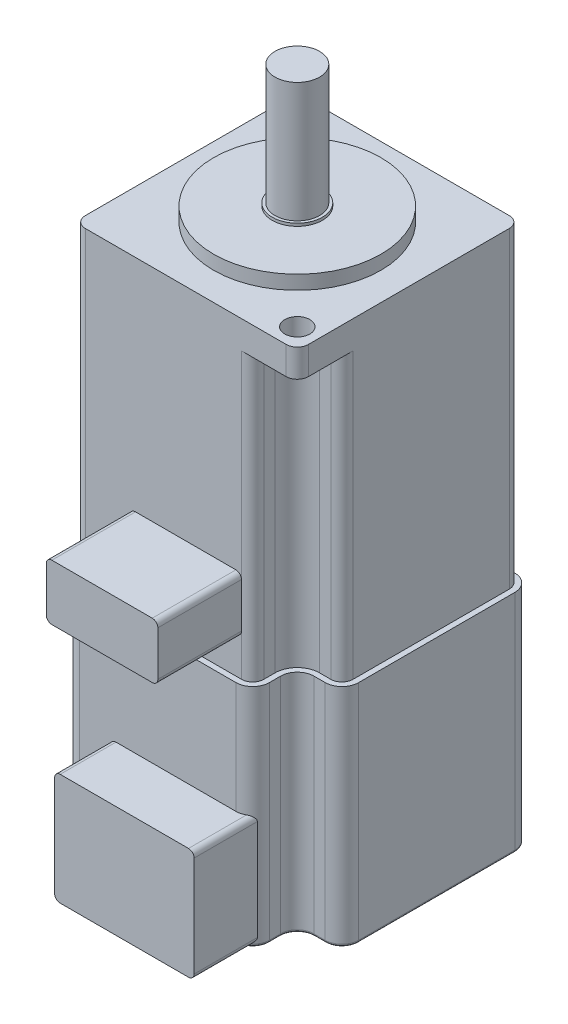
from build123d import *

# Parameters (mm, degrees)
BOSS_EXTRUDE1_DEPTH             = 5
SKETCH2_R                       = 15
BOSS_EXTRUDE2_DEPTH             = 2.5
SKETCH3_R                       = 2.25
CUT_EXTRUDE1_DEPTH              = 5
BOSS_EXTRUDE3_DEPTH             = 51
BOSS_EXTRUDE4_DEPTH             = 40.5
SKETCH6_R                       = 4.5
BOSS_EXTRUDE5_DEPTH             = 0.5
SKETCH7_R                       = 4
BOSS_EXTRUDE6_DEPTH             = 21.5
FILLET1_R                       = 0.5
BOSS_EXTRUDE7_DEPTH             = 15
BOSS_EXTRUDE8_DEPTH             = 10
BOSS_EXTRUDE8_DIRECTION_2_REACH = 44


with BuildPart() as part:
    # Sketch1 → Boss-Extrude1 (new body)
    with BuildSketch(Plane(origin=(0, 0, 0), x_dir=(1, 0, 0), z_dir=(0, 1, 0))):
        with BuildLine():
            Line((2, 0), (38, 0))
            ThreePointArc((38, 0), (39.414213562, 0.585786438), (40, 2))
            Line((40, 2), (40, 38))
            ThreePointArc((40, 38), (39.414213562, 39.414213562), (38, 40))
            Line((38, 40), (2, 40))
            ThreePointArc((2, 40), (0.585786438, 39.414213562), (0, 38))
            Line((0, 38), (0, 2))
            ThreePointArc((0, 2), (0.585786438, 0.585786438), (2, 0))
        make_face()
    extrude(amount=BOSS_EXTRUDE1_DEPTH)

    # Sketch2 → Boss-Extrude2 (add)
    with BuildSketch(Plane(origin=(0, 5, 0), x_dir=(1, 0, 0), z_dir=(0, 1, 0))):
        with Locations((20, 20)):
            Circle(SKETCH2_R)
    extrude(amount=BOSS_EXTRUDE2_DEPTH)

    # Sketch3 → Cut-Extrude1 (cut)
    with BuildSketch(Plane(origin=(0, 5, 0), x_dir=(1, 0, 0), z_dir=(0, 1, 0))):
        with Locations((3.736544033, 36.263455967)):
            Circle(SKETCH3_R)
        with Locations((36.263455967, 3.736544033)):
            Circle(SKETCH3_R)
    extrude(amount=-CUT_EXTRUDE1_DEPTH, mode=Mode.SUBTRACT)

    # Sketch4 → Boss-Extrude3 (add)
    with BuildSketch(Plane.XZ):
        with BuildLine():
            Line((32, -2), (32, -4))
            ThreePointArc((32, -4), (33.171572875, -6.828427125), (36, -8))
            Line((36, -8), (38, -8))
            ThreePointArc((38, -8), (39.414213562, -8.585786438), (40, -10))
            Line((40, -10), (40, -38))
            ThreePointArc((40, -38), (39.414213562, -39.414213562), (38, -40))
            Line((38, -40), (10, -40))
            ThreePointArc((10, -40), (8.585786438, -39.414213562), (8, -38))
            Line((8, -38), (8, -36))
            ThreePointArc((8, -36), (6.828427125, -33.171572875), (4, -32))
            Line((4, -32), (2, -32))
            ThreePointArc((2, -32), (0.585786438, -31.414213562), (0, -30))
            Line((0, -30), (0, -2))
            ThreePointArc((0, -2), (0.585786438, -0.585786438), (2, 0))
            Line((2, 0), (30, 0))
            ThreePointArc((30, 0), (31.414213562, -0.585786438), (32, -2))
        make_face()
    extrude(amount=BOSS_EXTRUDE3_DEPTH)

    # Sketch5 → Boss-Extrude4 (add)
    with BuildSketch(Plane.XZ.offset(51)):
        with BuildLine():
            Line((10, -41), (38, -41))
            ThreePointArc((38, -41), (40.121320344, -40.121320344), (41, -38))
            Line((41, -38), (41, -10))
            ThreePointArc((41, -10), (40.121320344, -7.878679656), (38, -7))
            Line((38, -7), (36, -7))
            ThreePointArc((36, -7), (33.878679656, -6.121320344), (33, -4))
            Line((33, -4), (33, -2))
            ThreePointArc((33, -2), (32.121320344, 0.121320344), (30, 1))
            Line((30, 1), (2, 1))
            ThreePointArc((2, 1), (-0.121320344, 0.121320344), (-1, -2))
            Line((-1, -2), (-1, -30))
            ThreePointArc((-1, -30), (-0.121320344, -32.121320344), (2, -33))
            Line((2, -33), (4, -33))
            ThreePointArc((4, -33), (6.121320344, -33.878679656), (7, -36))
            Line((7, -36), (7, -38))
            ThreePointArc((7, -38), (7.878679656, -40.121320344), (10, -41))
        make_face()
    extrude(amount=BOSS_EXTRUDE4_DEPTH)

    # Sketch6 → Boss-Extrude5 (add)
    with BuildSketch(Plane(origin=(0, 7.5, 0), x_dir=(1, 0, 0), z_dir=(0, 1, 0))):
        with Locations((20, 20)):
            Circle(SKETCH6_R)
    extrude(amount=BOSS_EXTRUDE5_DEPTH)

    # Sketch7 → Boss-Extrude6 (add)
    with BuildSketch(Plane(origin=(0, 8, 0), x_dir=(1, 0, 0), z_dir=(0, 1, 0))):
        with Locations((20, 20)):
            Circle(SKETCH7_R)
    extrude(amount=BOSS_EXTRUDE6_DEPTH)

    # Fillet1
    fillet1_edges = [part.edges().sort_by_distance(p)[0] for p in [
        (7.878679656, -91.5, -40.121320344),
        (24, -91.5, -41),
        (40.121320344, -91.5, -40.121320344),
        (41, -91.5, -24),
        (40.121320344, -91.5, -7.878679656),
        (37, -91.5, -7),
        (33.878679656, -91.5, -6.121320344),
        (33, -91.5, -3),
        (32.121320344, -91.5, 0.121320344),
        (16, -91.5, 1),
        (-0.121320344, -91.5, 0.121320344),
        (-1, -91.5, -16),
        (-0.121320344, -91.5, -32.121320344),
        (3, -91.5, -33),
        (6.121320344, -91.5, -33.878679656),
        (7, -91.5, -37),
    ]]
    fillet(fillet1_edges, radius=FILLET1_R)

    # Sketch8 → Boss-Extrude7 (add)
    with BuildSketch(Plane.XY):
        with BuildLine():
            Line((11, -34.5), (29, -34.5))
            ThreePointArc((29, -34.5), (29.707106781, -34.792893219), (30, -35.5))
            Line((30, -35.5), (30, -43.5))
            ThreePointArc((30, -43.5), (29.707106781, -44.207106781), (29, -44.5))
            Line((29, -44.5), (11, -44.5))
            ThreePointArc((11, -44.5), (10.292893219, -44.207106781), (10, -43.5))
            Line((10, -43.5), (10, -35.5))
            ThreePointArc((10, -35.5), (10.292893219, -34.792893219), (11, -34.5))
        make_face()
    extrude(amount=BOSS_EXTRUDE7_DEPTH)

    # Sketch9 → Boss-Extrude8 (add)
    with BuildSketch(Plane.XY.offset(1)):
        with BuildLine():
            Line((8.5, -71), (31.5, -71))
            ThreePointArc((31.5, -71), (32.207106781, -71.292893219), (32.5, -72))
            Line((32.5, -72), (32.5, -90))
            ThreePointArc((32.5, -90), (32.207106781, -90.707106781), (31.5, -91))
            Line((31.5, -91), (8.5, -91))
            ThreePointArc((8.5, -91), (7.792893219, -90.707106781), (7.5, -90))
            Line((7.5, -90), (7.5, -72))
            ThreePointArc((7.5, -72), (7.792893219, -71.292893219), (8.5, -71))
        make_face()
    extrude(amount=BOSS_EXTRUDE8_DEPTH)

    # Sketch9 → Boss-Extrude8 direction 2 (add, up to next)
    with BuildSketch(Plane.XY.offset(1), mode=Mode.PRIVATE) as boss_extrude8_direction_2_sk1:
        with BuildLine():
            Line((8.5, -71), (31.5, -71))
            ThreePointArc((31.5, -71), (32.207106781, -71.292893219), (32.5, -72))
            Line((32.5, -72), (32.5, -90))
            ThreePointArc((32.5, -90), (32.207106781, -90.707106781), (31.5, -91))
            Line((31.5, -91), (8.5, -91))
            ThreePointArc((8.5, -91), (7.792893219, -90.707106781), (7.5, -90))
            Line((7.5, -90), (7.5, -72))
            ThreePointArc((7.5, -72), (7.792893219, -71.292893219), (8.5, -71))
        make_face()
    boss_extrude8_direction_2_tool1 = extrude(boss_extrude8_direction_2_sk1.sketch, amount=-BOSS_EXTRUDE8_DIRECTION_2_REACH, mode=Mode.PRIVATE) - part.part
    add(boss_extrude8_direction_2_tool1.solids().sort_by_distance((20, -81, 1))[0])


solid = part.part
